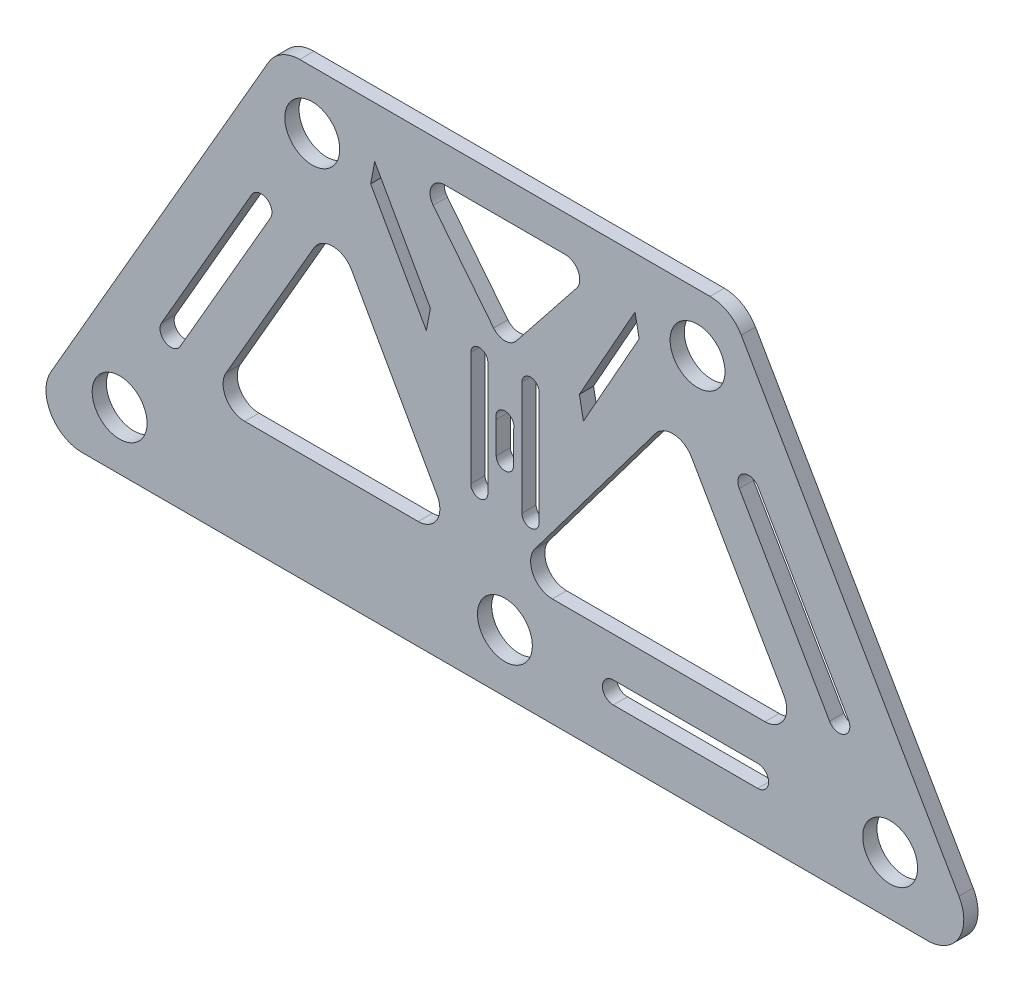
from build123d import *

# Parameters (mm, degrees)
SKETCH1_R           = 9.65
BOSS_EXTRUDE1_DEPTH = 2.5
CUT_EXTRUDE2_DEPTH  = 6
FILLET1_R           = 7.62
SKETCH3_R           = 3.175
CUT_EXTRUDE3_DEPTH  = 31.75
CUT_EXTRUDE4_DEPTH  = 6


with BuildPart() as part:
    # Sketch1 → Boss-Extrude1 (new body, symmetric)
    with BuildSketch(Plane.XY):
        with BuildLine():
            ThreePointArc((-148.66489382, -20.32), (-159.663416448, -13.97), (-159.663416448, -1.27))
            Line((-159.663416448, -1.27), (-83.131265013, 131.287574699))
            ThreePointArc((-83.131265013, 131.287574699), (-78.482742385, 135.936097327), (-72.132742385, 137.637574699))
            Line((-72.132742385, 137.637574699), (72.132742385, 137.637574699))
            ThreePointArc((72.132742385, 137.637574699), (78.482742385, 135.936097327), (83.131265013, 131.287574699))
            Line((83.131265013, 131.287574699), (159.663416448, -1.27))
            ThreePointArc((159.663416448, -1.27), (159.663416448, -13.97), (148.66489382, -20.32))
            Line((148.66489382, -20.32), (-148.66489382, -20.32))
        make_face()
        Circle(SKETCH1_R, mode=Mode.SUBTRACT)
        with Locations((-135.466666667, 0)):
            Circle(SKETCH1_R, mode=Mode.SUBTRACT)
        with Locations((135.466666667, 0)):
            Circle(SKETCH1_R, mode=Mode.SUBTRACT)
        with Locations((-67.733333333, 117.317574699)):
            Circle(SKETCH1_R, mode=Mode.SUBTRACT)
        with Locations((67.733333333, 117.317574699)):
            Circle(SKETCH1_R, mode=Mode.SUBTRACT)
    extrude(amount=BOSS_EXTRUDE1_DEPTH, both=True)

    # Sketch2 → Cut-Extrude2 (cut, through all)
    with BuildSketch(Plane.XY.offset(2.5)):
        Polygon((-17.476488174, 17.78), (-60.462836348, 94.350444874), (-104.670803308, 17.78), align=None)
        Polygon((59.840980548, 95.427530715), (1.38432688, 17.78), (104.670803308, 17.78), align=None)
    extrude(amount=-CUT_EXTRUDE2_DEPTH, mode=Mode.SUBTRACT)

    # Fillet1
    fillet1_edges = [part.edges().sort_by_distance(p)[0] for p in [
        (-17.476488174, 17.78, 0),
        (-104.670803308, 17.78, 0),
        (-60.462836348, 94.350444874, 0),
        (59.840980548, 95.427530715, 0),
        (104.670803308, 17.78, 0),
        (1.38432688, 17.78, 0),
    ]]
    fillet(fillet1_edges, radius=FILLET1_R)

    # Sketch3 → Cut-Extrude3 (cut)
    with BuildSketch(Plane.XY.offset(2.5)):
        with Locations((0, 63.5)):
            Circle(SKETCH3_R)
    extrude(amount=-CUT_EXTRUDE3_DEPTH, mode=Mode.SUBTRACT)

    # Sketch4 → Cut-Extrude4 (cut, through all)
    with BuildSketch(Plane.XY.offset(2.5)):
        with BuildLine():
            Line((-114.175443212, 29.25748078), (-82.425443212, 84.25009392))
            ThreePointArc((-82.425443212, 84.25009392), (-83.82, 89.454650708), (-89.024556788, 88.06009392))
            Line((-89.024556788, 88.06009392), (-120.774556788, 33.06748078))
            ThreePointArc((-120.774556788, 33.06748078), (-119.38, 27.862923991), (-114.175443212, 29.25748078))
        make_face()
        Polygon((-47.20148926, 112.237574699), (-27.620295809, 77.358112791), (-26.188384166, 84.842364861), (-45.769577617, 119.721826769), align=None)
        Polygon((45.769577617, 119.721826769), (26.188384166, 84.842364861), (27.620295809, 77.358112791), (47.20148926, 112.237574699), align=None)
        with BuildLine():
            Line((3.978915409, 89.950381514), (25.210877866, 116.699310593))
            ThreePointArc((25.210877866, 116.699310593), (25.806368519, 122.066920569), (21.231962456, 124.937574699))
            Line((21.231962456, 124.937574699), (-21.231962456, 124.937574699))
            ThreePointArc((-21.231962456, 124.937574699), (-25.806368519, 122.066920569), (-25.210877866, 116.699310593))
            Line((-25.210877866, 116.699310593), (-3.978915409, 89.950381514))
            ThreePointArc((-3.978915409, 89.950381514), (0, 88.028645621), (3.978915409, 89.950381514))
        make_face()
        with BuildLine():
            Line((82.425443212, 84.25009392), (114.175443212, 29.25748078))
            ThreePointArc((114.175443212, 29.25748078), (119.38, 27.862923991), (120.774556788, 33.06748078))
            Line((120.774556788, 33.06748078), (89.024556788, 88.06009392))
            ThreePointArc((89.024556788, 88.06009392), (83.82, 89.454650708), (82.425443212, 84.25009392))
        make_face()
        with BuildLine():
            Line((88.9, 3.81), (38.1, 3.81))
            ThreePointArc((38.1, 3.81), (34.29, 0), (38.1, -3.81))
            Line((38.1, -3.81), (88.9, -3.81))
            ThreePointArc((88.9, -3.81), (92.71, 0), (88.9, 3.81))
        make_face()
        with BuildLine():
            Line((-3.05, 63.5), (-3.05, 51.5))
            ThreePointArc((-3.05, 51.5), (0, 48.45), (3.05, 51.5))
            Line((3.05, 51.5), (3.05, 63.5))
            ThreePointArc((3.05, 63.5), (0, 66.55), (-3.05, 63.5))
        make_face()
        with BuildLine():
            Line((6, 78.5), (6, 38.5))
            ThreePointArc((6, 38.5), (9, 35.5), (12, 38.5))
            Line((12, 38.5), (12, 78.5))
            ThreePointArc((12, 78.5), (9, 81.5), (6, 78.5))
        make_face()
        with BuildLine():
            Line((-12, 78.5), (-12, 38.5))
            ThreePointArc((-12, 38.5), (-9, 35.5), (-6, 38.5))
            Line((-6, 38.5), (-6, 78.5))
            ThreePointArc((-6, 78.5), (-9, 81.5), (-12, 78.5))
        make_face()
    extrude(amount=-CUT_EXTRUDE4_DEPTH, mode=Mode.SUBTRACT)


solid = part.part
